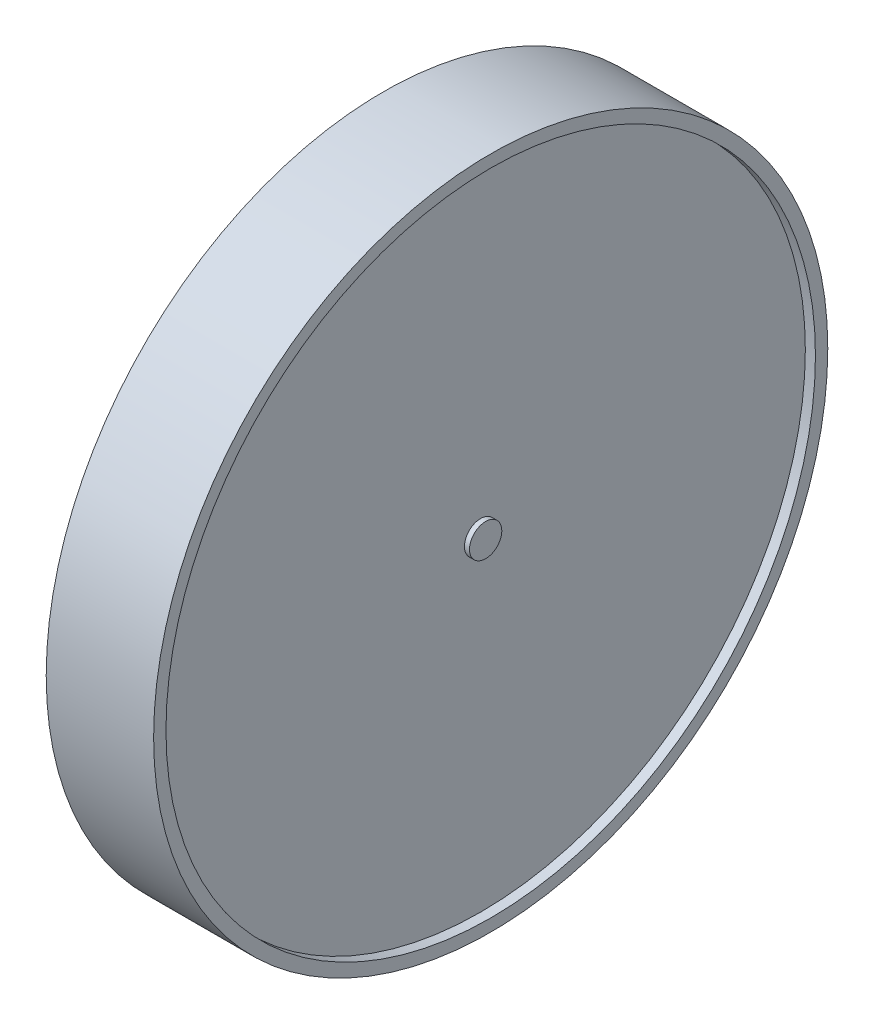
from build123d import *


with BuildPart() as part:
    # Croquis1 → Revolución1 (revolve)
    with BuildSketch(Plane(origin=(0, 0, 0), x_dir=(1, 0, 0), z_dir=(0, 1, 0))):
        Polygon((0, 49.85060685), (0, -87.230621082), (45.880416528, -87.230621082), (45.880416528, -81.958767162), (41.565871711, -81.958767162), (41.565871711, 49.85060685), (43.72314412, 49.85060685), (43.72314412, 56.746010246), (0, 56.746010246), align=None)
    revolve(axis=Axis((43.72314412, 0, -56.746010246), (-1, 0, 0)))


solid = part.part
